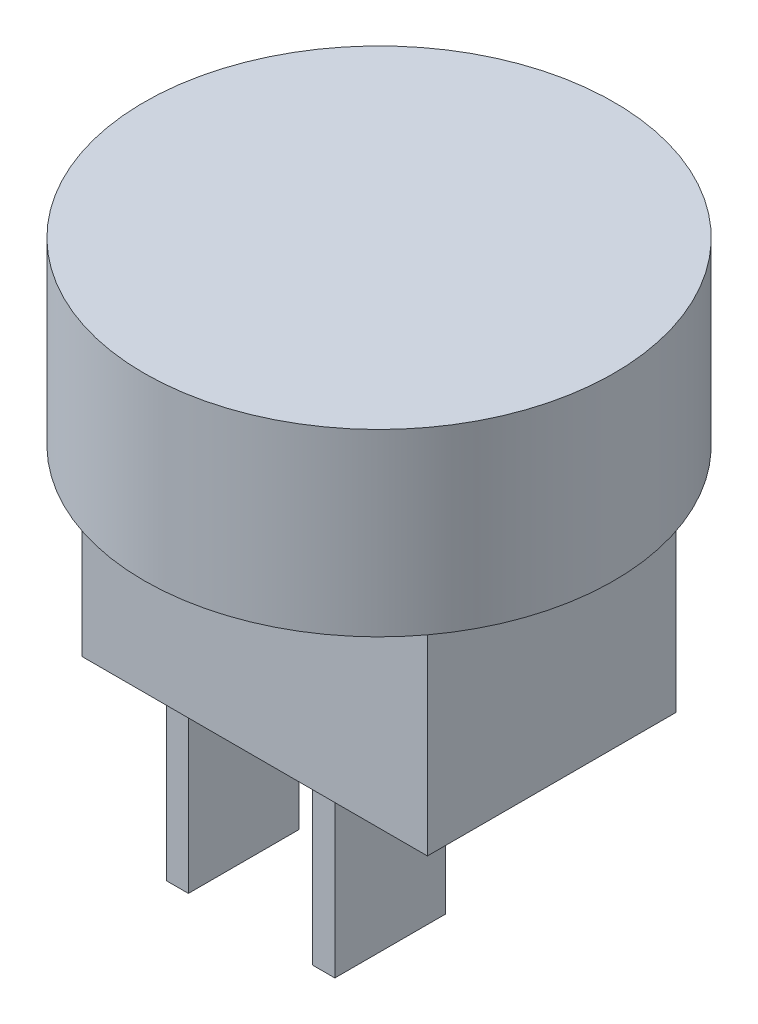
from build123d import *

# Parameters (mm, degrees)
SKICA2_W                = 12.5
SKICA2_H                = 9
P_IDAT_VYSUNUT_M1_DEPTH = 7.5
SKICA3_R                = 8.5
P_IDAT_VYSUNUT_M2_DEPTH = 6.5
SKICA4_W                = 0.8
SKICA4_H                = 4
P_IDAT_VYSUNUT_M3_DEPTH = 8


with BuildPart() as part:
    # Skica2 → Přidat vysunutím1 (new body)
    with BuildSketch(Plane(origin=(0, 0, 0), x_dir=(1, 0, 0), z_dir=(0, 1, 0))):
        Rectangle(SKICA2_W, SKICA2_H)
    extrude(amount=P_IDAT_VYSUNUT_M1_DEPTH)

    # Skica3 → Přidat vysunutím2 (add)
    with BuildSketch(Plane(origin=(0, 7.5, 0), x_dir=(1, 0, 0), z_dir=(0, 1, 0))):
        Circle(SKICA3_R)
    extrude(amount=P_IDAT_VYSUNUT_M2_DEPTH)

    # Skica4 → Přidat vysunutím3 (add)
    with BuildSketch(Plane(origin=(0, 0, 0), x_dir=(-1, 0, 0), z_dir=(0, -1, 0))):
        with Locations((5.3, 0)):
            Rectangle(SKICA4_W, SKICA4_H)
        Rectangle(SKICA4_W, SKICA4_H)
    extrude(amount=P_IDAT_VYSUNUT_M3_DEPTH)


solid = part.part
